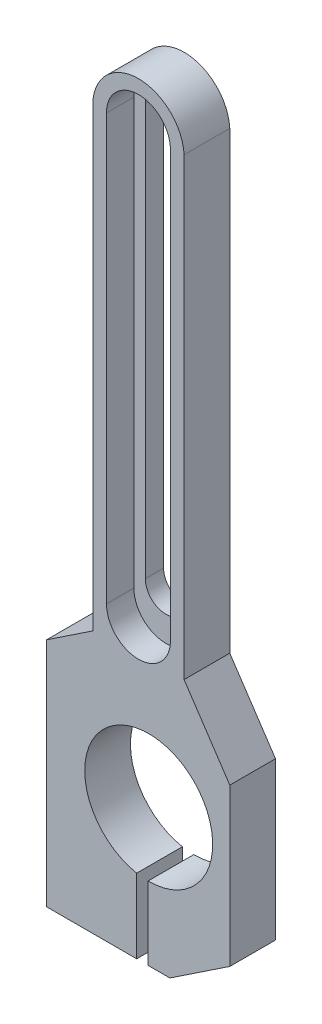
from build123d import *

# Parameters (mm, degrees)
BOSS_EXTRUDE1_DEPTH = 10
CUT_EXTRUDE1_DEPTH  = 6
SKETCH3_R           = 14
CUT_EXTRUDE2_DEPTH  = 100
SKETCH4_W           = 2.485456217
SKETCH4_H           = 52.416620737
CUT_EXTRUDE3_DEPTH  = 100


with BuildPart() as part:
    # Sketch1 → Boss-Extrude1 (new body)
    with BuildSketch(Plane.XY):
        with BuildLine():
            Line((-3.679977182, -54.534954407), (4.628170727, -54.534954407))
            Line((4.628170727, -54.534954407), (17.741392821, -45.792806344))
            Line((17.741392821, -45.792806344), (17.741392821, -11.427332251))
            Line((17.741392821, -11.427332251), (7.741392821, 3.572667749))
            Line((7.741392821, 3.572667749), (7.741392821, 103.024920211))
            ThreePointArc((7.741392821, 103.024920211), (-2.457335357, 112.462746672), (-12.242059824, 102.596349566))
            Line((-12.242059824, 102.596349566), (-12.242059824, 2.804284439))
            Line((-12.242059824, 2.804284439), (-22.364938744, -3.944301507))
            Line((-22.364938744, -3.944301507), (-22.364938744, -54.534954407))
            Line((-22.364938744, -54.534954407), (-3.679977182, -54.534954407))
        make_face()
        with BuildLine():
            Line((2.257078102, 102.465045593), (2.257078102, 12.465045593))
            ThreePointArc((2.257078102, 12.465045593), (-2.242921898, 7.965045593), (-6.742921898, 12.465045593))
            Line((-6.742921898, 12.465045593), (-6.742921898, 102.465045593))
            ThreePointArc((-6.742921898, 102.465045593), (-2.242921898, 106.965045593), (2.257078102, 102.465045593))
        make_face(mode=Mode.SUBTRACT)
    extrude(amount=BOSS_EXTRUDE1_DEPTH)

    # Sketch2 → Cut-Extrude1 (cut)
    with BuildSketch(Plane.XY.offset(10)):
        with BuildLine():
            Line((4.757078102, 102.465045593), (4.757078102, 9.430262407))
            ThreePointArc((4.757078102, 9.430262407), (-2.242921898, 2.430262407), (-9.242921898, 9.430262407))
            Line((-9.242921898, 9.430262407), (-9.242921898, 102.465045593))
            ThreePointArc((-9.242921898, 102.465045593), (-2.242921898, 109.465045593), (4.757078102, 102.465045593))
        make_face()
    extrude(amount=-CUT_EXTRUDE1_DEPTH, mode=Mode.SUBTRACT)

    # Sketch3 → Cut-Extrude2 (cut)
    with BuildSketch(Plane.XY.offset(10)):
        with Locations((0, -24.534954407)):
            Circle(SKETCH3_R)
    extrude(amount=-CUT_EXTRUDE2_DEPTH, mode=Mode.SUBTRACT)

    # Sketch4 → Cut-Extrude3 (cut)
    with BuildSketch(Plane.XY.offset(10)):
        with Locations((-1.385400928, -52.416791412)):
            Rectangle(SKETCH4_W, SKETCH4_H)
    extrude(amount=-CUT_EXTRUDE3_DEPTH, mode=Mode.SUBTRACT)


solid = part.part
